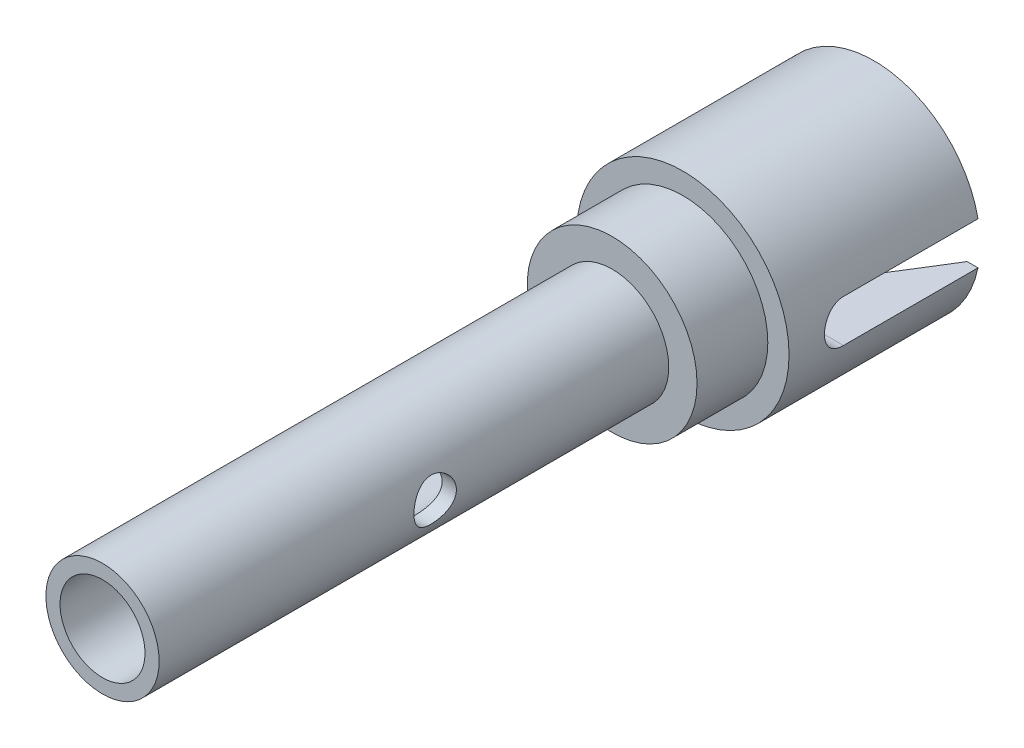
from build123d import *

# Parameters (mm, degrees)
CUT_EXTRUDE1_DEPTH      = 8.5
CUT_EXTRUDE1_DEPTH_BACK = 8.5
SKETCH3_R               = 3.75
CUT_EXTRUDE2_DEPTH      = 11.5
CHAMFER1_SIZE           = 3
CHAMFER1_SIZE2          = 5
CHAMFER1_PART_2_SIZE    = 3
CHAMFER1_PART_2_SIZE2   = 5
SKETCH4_R               = 3
CUT_EXTRUDE3_DEPTH      = 27.5
SKETCH5_R               = 1.5
CUT_EXTRUDE4_DEPTH      = 8.5000001
CUT_EXTRUDE4_DEPTH_BACK = 8.5000001


with BuildPart() as part:
    # Sketch1 → Revolve1 (revolve)
    with BuildSketch(Plane(origin=(0, 0, 0), x_dir=(0, 0, -1), z_dir=(1, 0, 0))):
        Polygon((0, 4), (36, 4), (36, 6), (41, 6), (41, 7.5), (54.5, 7.5), (54.5, 0), (0, 0), align=None)
    revolve(axis=Axis((0, 0, 0), (0, 0, -1)))

    # Sketch2 → Cut-Extrude1 (cut, two sides)
    with BuildSketch(Plane(origin=(0, 0, 0), x_dir=(0, 0, -1), z_dir=(1, 0, 0))) as cut_extrude1_sk:
        with BuildLine():
            Line((54.5, -1.5), (45, -1.5))
            ThreePointArc((45, -1.5), (43.5, 0), (45, 1.5))
            Line((45, 1.5), (54.5, 1.5))
            ThreePointArc((54.5, 1.5), (56, 0), (54.5, -1.5))
        make_face()
    extrude(amount=CUT_EXTRUDE1_DEPTH, mode=Mode.SUBTRACT)
    extrude(cut_extrude1_sk.sketch, amount=-CUT_EXTRUDE1_DEPTH_BACK, mode=Mode.SUBTRACT)

    # Sketch3 → Cut-Extrude2 (cut)
    with BuildSketch(Plane(origin=(0, 0, -54.5), x_dir=(-1, 0, 0), z_dir=(0, 0, -1))):
        Circle(SKETCH3_R)
    extrude(amount=-CUT_EXTRUDE2_DEPTH, mode=Mode.SUBTRACT)

    # Chamfer1
    chamfer1_edges = [part.edges().sort_by_distance(p)[0] for p in [
        (0, -3.75, -54.5),
    ]]
    chamfer1_side = [part.faces().sort_by_distance(p)[0] for p in [
        (0, -4.328722243, -54.5),
    ]]
    chamfer(chamfer1_edges, length=CHAMFER1_SIZE, length2=CHAMFER1_SIZE2, reference=chamfer1_side[0])

    # Chamfer1 part 2
    chamfer1_part_2_edges = [part.edges().sort_by_distance(p)[0] for p in [
        (0, 3.75, -54.5),
    ]]
    chamfer1_part_2_side = [part.faces().sort_by_distance(p)[0] for p in [
        (0, 4.328722243, -54.5),
    ]]
    chamfer(chamfer1_part_2_edges, length=CHAMFER1_PART_2_SIZE, length2=CHAMFER1_PART_2_SIZE2, reference=chamfer1_part_2_side[0])

    # Sketch4 → Cut-Extrude3 (cut)
    with BuildSketch(Plane.XY):
        Circle(SKETCH4_R)
    extrude(amount=-CUT_EXTRUDE3_DEPTH, mode=Mode.SUBTRACT)

    # Sketch5 → Cut-Extrude4 (cut, two sides)
    with BuildSketch(Plane(origin=(0, 0, 0), x_dir=(0, -1, 0), z_dir=(1, 0, 0))) as cut_extrude4_sk:
        with Locations((0, 19.5)):
            Circle(SKETCH5_R)
    extrude(amount=CUT_EXTRUDE4_DEPTH, mode=Mode.SUBTRACT)
    extrude(cut_extrude4_sk.sketch, amount=-CUT_EXTRUDE4_DEPTH_BACK, mode=Mode.SUBTRACT)


solid = part.part
